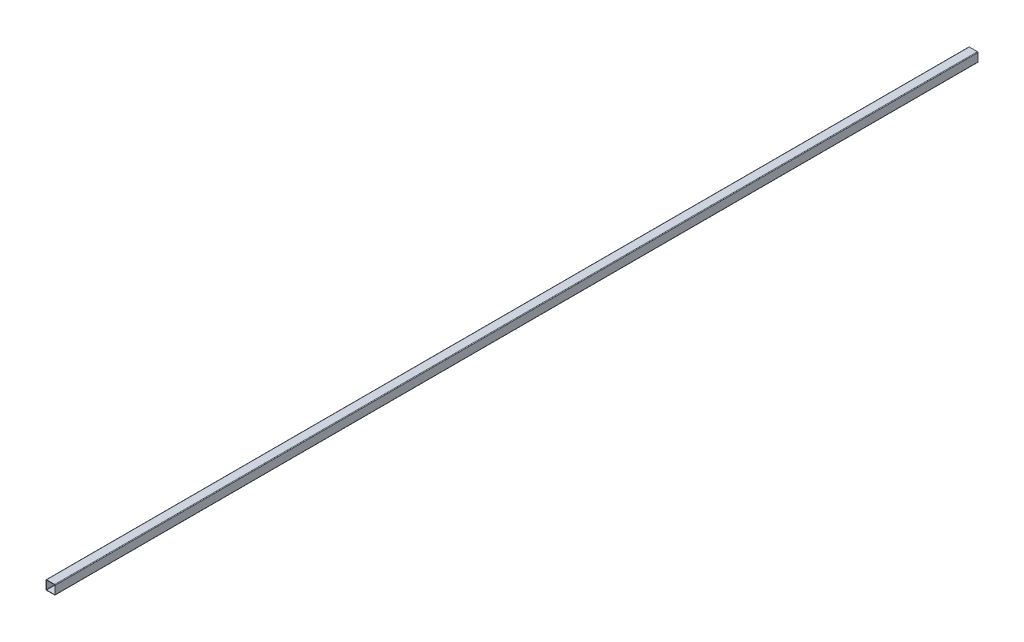
from build123d import *

# Parameters (mm, degrees)
EXTRUDE_1_DEPTH = 3000


with BuildPart() as part:
    # Эскиз1 → Бобышка-Вытянуть1 (new body)
    with BuildSketch(Plane.XY):
        with BuildLine():
            Line((-13, 15), (13, 15))
            ThreePointArc((13, 15), (14.414213562, 14.414213562), (15, 13))
            Line((15, 13), (15, -13))
            ThreePointArc((15, -13), (14.414213562, -14.414213562), (13, -15))
            Line((13, -15), (-13, -15))
            ThreePointArc((-13, -15), (-14.414213562, -14.414213562), (-15, -13))
            Line((-15, -13), (-15, 13))
            ThreePointArc((-15, 13), (-14.414213562, 14.414213562), (-13, 15))
        make_face()
        with BuildLine():
            Line((-13, 14), (13, 14))
            ThreePointArc((13, 14), (13.707106781, 13.707106781), (14, 13))
            Line((14, 13), (14, -13))
            ThreePointArc((14, -13), (13.707106781, -13.707106781), (13, -14))
            Line((13, -14), (-13, -14))
            ThreePointArc((-13, -14), (-13.707106781, -13.707106781), (-14, -13))
            Line((-14, -13), (-14, 13))
            ThreePointArc((-14, 13), (-13.707106781, 13.707106781), (-13, 14))
        make_face(mode=Mode.SUBTRACT)
    extrude(amount=EXTRUDE_1_DEPTH)


solid = part.part
